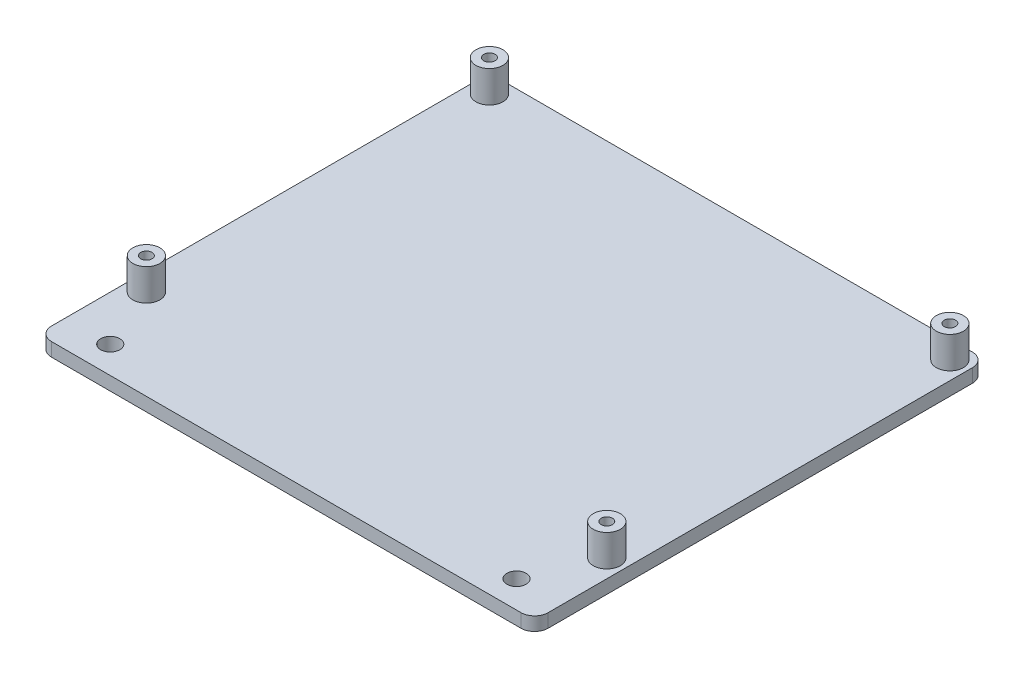
from build123d import *

# Parameters (mm, degrees)
SKETCH1_R           = 1.25
BOSS_EXTRUDE1_DEPTH = 3
FILLET1_R           = 3
SKETCH2_R           = 3
SKETCH2_R_2         = 1.25
BOSS_EXTRUDE2_DEPTH = 7
SKETCH4_R           = 2.125
CUT_EXTRUDE1_DEPTH  = 11


with BuildPart() as part:
    # Sketch1 → Boss-Extrude1 (new body)
    with BuildSketch(Plane(origin=(0, 0, 0), x_dir=(1, 0, 0), z_dir=(0, 1, 0))):
        Polygon((0, 0), (110, 0), (110, 16), (110, 100), (0, 100), (0, 16), align=None)
        with Locations((4, 96)):
            Circle(SKETCH1_R, mode=Mode.SUBTRACT)
        with Locations((106, 96)):
            Circle(SKETCH1_R, mode=Mode.SUBTRACT)
        with Locations((106, 20)):
            Circle(SKETCH1_R, mode=Mode.SUBTRACT)
        with Locations((4, 20)):
            Circle(SKETCH1_R, mode=Mode.SUBTRACT)
    extrude(amount=BOSS_EXTRUDE1_DEPTH)

    # Fillet1
    fillet1_edges = [part.edges().sort_by_distance(p)[0] for p in [
        (0, 1.5, -100),
        (110, 1.5, -100),
        (110, 1.5, 0),
        (0, 1.5, 0),
    ]]
    fillet(fillet1_edges, radius=FILLET1_R)

    # Sketch2 → Boss-Extrude2 (add)
    with BuildSketch(Plane(origin=(0, 3, 0), x_dir=(1, 0, 0), z_dir=(0, 1, 0))):
        with Locations((4, 96)):
            Circle(SKETCH2_R)
        with Locations((4, 96)):
            Circle(SKETCH2_R_2, mode=Mode.SUBTRACT)
        with Locations((106, 96)):
            Circle(SKETCH2_R)
        with Locations((106, 96)):
            Circle(SKETCH2_R_2, mode=Mode.SUBTRACT)
        with Locations((106, 20)):
            Circle(SKETCH2_R)
        with Locations((106, 20)):
            Circle(SKETCH2_R_2, mode=Mode.SUBTRACT)
        with Locations((4, 20)):
            Circle(SKETCH2_R)
        with Locations((4, 20)):
            Circle(SKETCH2_R_2, mode=Mode.SUBTRACT)
    extrude(amount=BOSS_EXTRUDE2_DEPTH)

    # Sketch4 → Cut-Extrude1 (cut, through all)
    with BuildSketch(Plane.XZ):
        with Locations((10, -6)):
            Circle(SKETCH4_R)
        with Locations((100, -6)):
            Circle(SKETCH4_R)
    extrude(amount=-CUT_EXTRUDE1_DEPTH, mode=Mode.SUBTRACT)


solid = part.part
